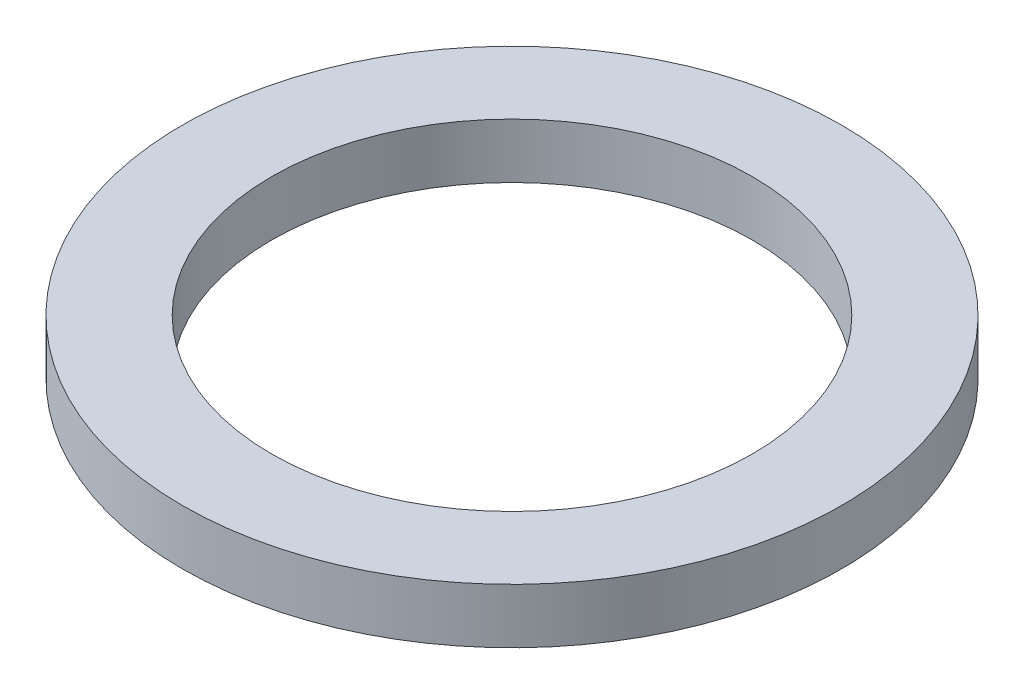
from build123d import *

# Parameters (mm, degrees)
SKETCH1_R           = 76.2
SKETCH1_R_2         = 55.5625
BOSS_EXTRUDE1_DEPTH = 12.7


with BuildPart() as part:
    # Sketch1 → Boss-Extrude1 (new body)
    with BuildSketch(Plane(origin=(0, 0, 0), x_dir=(1, 0, 0), z_dir=(0, 1, 0))):
        Circle(SKETCH1_R)
        Circle(SKETCH1_R_2, mode=Mode.SUBTRACT)
    extrude(amount=BOSS_EXTRUDE1_DEPTH)


solid = part.part
